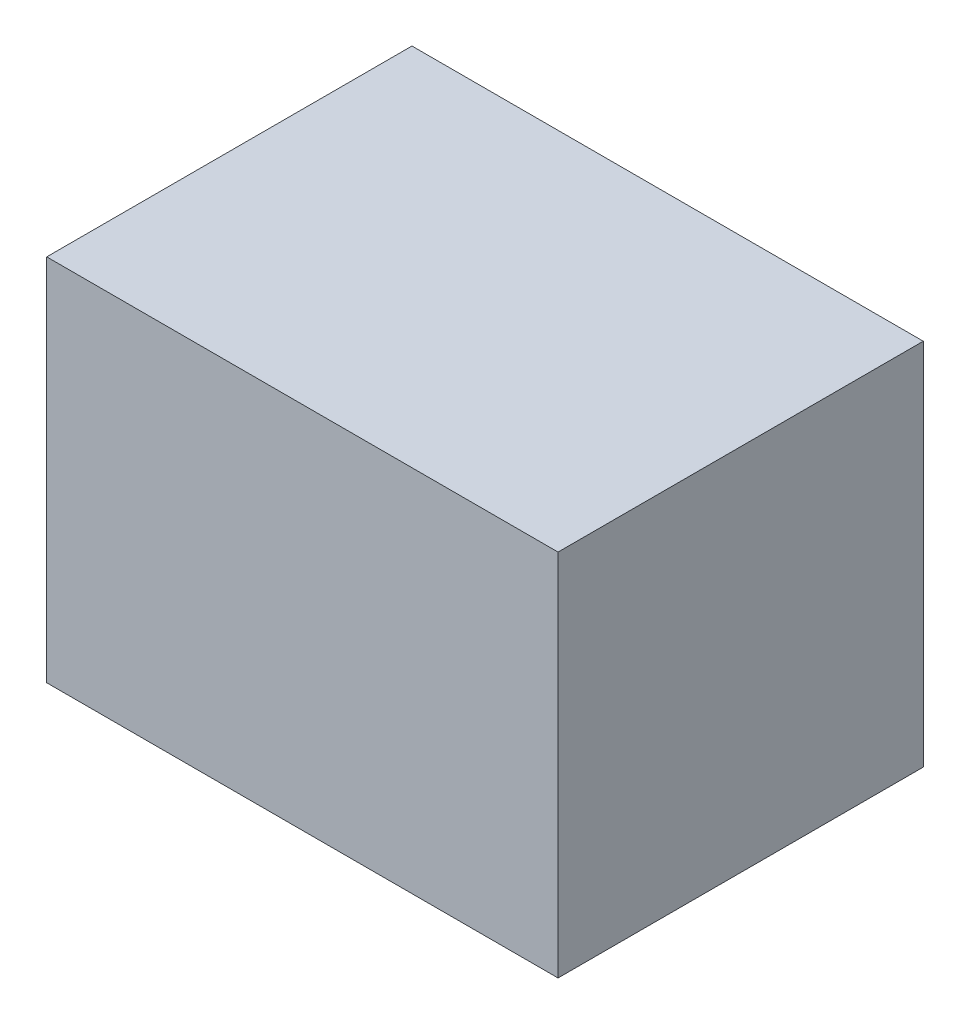
from build123d import *

# Parameters (mm, degrees)
SKETCH1_W           = 140
SKETCH1_H           = 100
BOSS_EXTRUDE1_DEPTH = 100
SHELL1_T            = -1
SKETCH2_W           = 140
SKETCH2_H           = 100
BOSS_EXTRUDE2_DEPTH = 1


with BuildPart() as part:
    # Sketch1 → Boss-Extrude1 (new body)
    with BuildSketch(Plane.XY):
        Rectangle(SKETCH1_W, SKETCH1_H)
    extrude(amount=BOSS_EXTRUDE1_DEPTH)

    # Shell1
    shell1_openings = [part.faces().sort_by_distance(p)[0] for p in [
        (0, 50, 50),
    ]]
    offset(amount=SHELL1_T, openings=shell1_openings, kind=Kind.INTERSECTION)

    # Sketch2 → Boss-Extrude2 (add)
    with BuildSketch(Plane(origin=(0, 50, 0), x_dir=(1, 0, 0), z_dir=(0, 1, 0))):
        with Locations((0, -50)):
            Rectangle(SKETCH2_W, SKETCH2_H)
    extrude(amount=BOSS_EXTRUDE2_DEPTH)


solid = part.part
